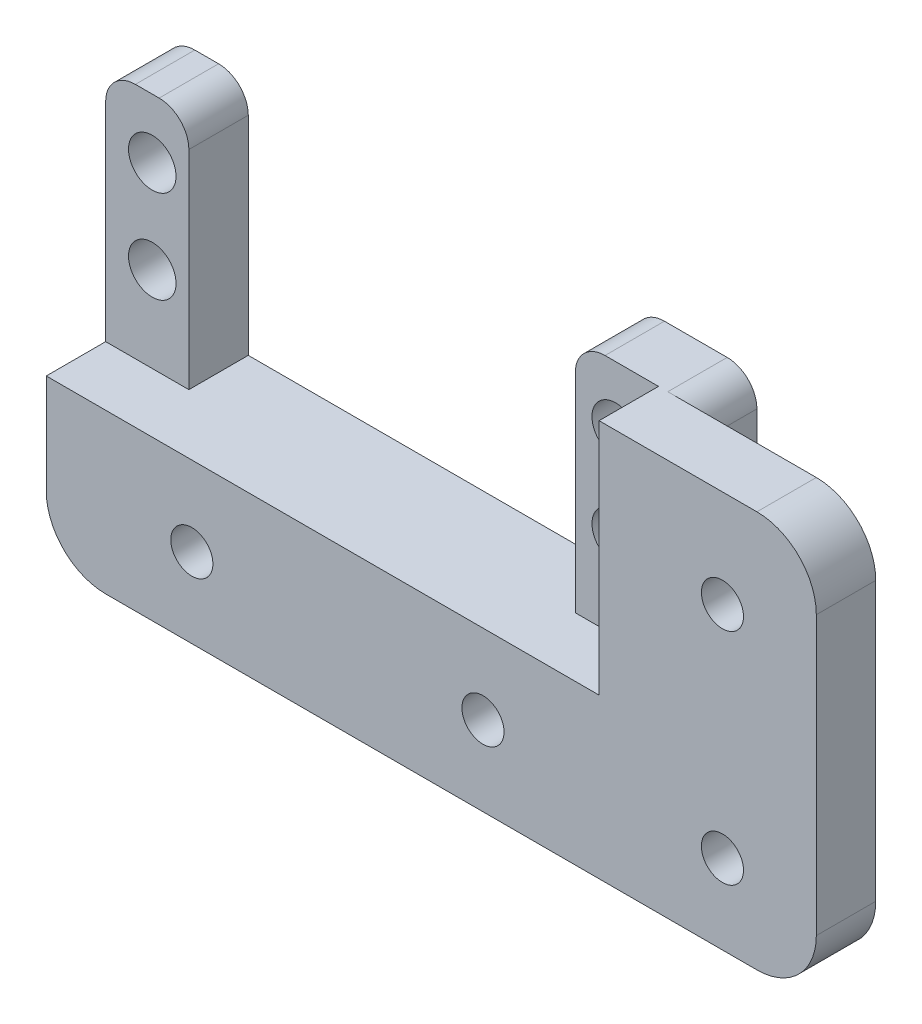
from build123d import *

# Parameters (mm, degrees)
BOSS_EXTRUDE1_DEPTH = 12.7
BOSS_EXTRUDE2_DEPTH = 25.4
SKETCH4_W           = 8.89
SKETCH4_H           = 6.35
BOSS_EXTRUDE3_DEPTH = 25.4
SKETCH5_R           = 2.54
CUT_EXTRUDE1_DEPTH  = 7.35
SKETCH6_W           = 20.066
SKETCH6_H           = 42.4
SKETCH6_R           = 2.25
BOSS_EXTRUDE4_DEPTH = 12.7
SKETCH7_R           = 6.35
SKETCH7_R_2         = 2.25
CUT_EXTRUDE2_DEPTH  = 6.35
SKETCH8_W           = 19.05
SKETCH8_H           = 42.4
CUT_EXTRUDE3_DEPTH  = 6.35
FILLET1_R           = 6.35
FILLET2_R           = 3.175


with BuildPart() as part:
    # Sketch1 → Boss-Extrude1 (new body)
    with BuildSketch(Plane.XY):
        Polygon((3833.667818581, -3.138), (3791.065892699, -3.138), (3781.25185564, -8.5), (3843.48185564, -8.5), align=None)
        with BuildLine():
            Line((3825.67435564, 0), (3799.05935564, 0))
            ThreePointArc((3799.05935564, 0), (3797.366063058, -2.180040562), (3794.834842884, -1.078795335))
            Line((3794.834842884, -1.078795335), (3791.065892699, -3.138))
            Line((3791.065892699, -3.138), (3833.667818581, -3.138))
            Line((3833.667818581, -3.138), (3829.898868396, -1.078795335))
            ThreePointArc((3829.898868396, -1.078795335), (3827.367648222, -2.180040562), (3825.67435564, 0))
        make_face()
        with BuildLine():
            Line((3843.48185564, -3.138), (3843.48185564, 0))
            Line((3843.48185564, 0), (3830.17435564, 0))
            ThreePointArc((3830.17435564, 0), (3830.104396202, -0.556707418), (3829.898868396, -1.078795335))
            Line((3829.898868396, -1.078795335), (3833.667818581, -3.138))
            Line((3833.667818581, -3.138), (3843.48185564, -3.138))
        make_face()
        Polygon((3812.36685564, 8.5), (3822.180892699, 3.138), (3843.48185564, 3.138), (3843.48185564, 8.5), align=None)
        with BuildLine():
            Line((3843.48185564, 3.138), (3822.180892699, 3.138))
            Line((3822.180892699, 3.138), (3825.949842884, 1.078795335))
            ThreePointArc((3825.949842884, 1.078795335), (3828.481063058, 2.180040562), (3830.17435564, 0))
            Line((3830.17435564, 0), (3843.48185564, 0))
            Line((3843.48185564, 0), (3843.48185564, 3.138))
        make_face()
        with BuildLine():
            Line((3822.180892699, 3.138), (3802.552818581, 3.138))
            Line((3802.552818581, 3.138), (3798.783868396, 1.078795335))
            ThreePointArc((3798.783868396, 1.078795335), (3798.989396202, 0.556707418), (3799.05935564, 0))
            Line((3799.05935564, 0), (3825.67435564, 0))
            ThreePointArc((3825.67435564, 0), (3825.744315078, 0.556707418), (3825.949842884, 1.078795335))
            Line((3825.949842884, 1.078795335), (3822.180892699, 3.138))
        make_face()
        Polygon((3812.36685564, 8.5), (3802.552818581, 3.138), (3822.180892699, 3.138), align=None)
        Polygon((3781.25185564, 8.5), (3781.25185564, 3.138), (3802.552818581, 3.138), (3812.36685564, 8.5), align=None)
        with BuildLine():
            Line((3802.552818581, 3.138), (3781.25185564, 3.138))
            Line((3781.25185564, 3.138), (3781.25185564, 0))
            Line((3781.25185564, 0), (3794.55935564, 0))
            ThreePointArc((3794.55935564, 0), (3796.252648222, 2.180040562), (3798.783868396, 1.078795335))
            Line((3798.783868396, 1.078795335), (3802.552818581, 3.138))
        make_face()
        with BuildLine():
            Line((3794.55935564, 0), (3781.25185564, 0))
            Line((3781.25185564, 0), (3781.25185564, -3.138))
            Line((3781.25185564, -3.138), (3791.065892699, -3.138))
            Line((3791.065892699, -3.138), (3794.834842884, -1.078795335))
            ThreePointArc((3794.834842884, -1.078795335), (3794.629315078, -0.556707418), (3794.55935564, 0))
        make_face()
        Polygon((3791.065892699, -3.138), (3781.25185564, -3.138), (3781.25185564, -8.5), align=None)
        Polygon((3843.48185564, -3.138), (3833.667818581, -3.138), (3843.48185564, -8.5), align=None)
    extrude(amount=BOSS_EXTRUDE1_DEPTH)

    # Sketch3 → Boss-Extrude2 (add)
    with BuildSketch(Plane(origin=(0, 8.5, 0), x_dir=(1, 0, 0), z_dir=(0, 1, 0))):
        Polygon((3831.44225564, 0), (3831.44225564, -6.35), (3840.33225564, -6.35), (3840.33225564, -12.7), (3843.48185564, -12.7), (3843.48185564, 0), align=None)
    extrude(amount=BOSS_EXTRUDE2_DEPTH)

    # Sketch4 → Boss-Extrude3 (add)
    with BuildSketch(Plane(origin=(0, 8.5, 0), x_dir=(1, 0, 0), z_dir=(0, 1, 0))):
        with Locations((3785.69685564, -3.175)):
            Rectangle(SKETCH4_W, SKETCH4_H)
    extrude(amount=BOSS_EXTRUDE3_DEPTH)

    # Sketch5 → Cut-Extrude1 (cut, through all)
    with BuildSketch(Plane.XY.offset(6.35)):
        with Locations((3835.76025564, 27.55)):
            Circle(SKETCH5_R)
        with Locations((3835.76025564, 17.644)):
            Circle(SKETCH5_R)
        with Locations((3786.23025564, 17.644)):
            Circle(SKETCH5_R)
        with Locations((3786.23025564, 27.55)):
            Circle(SKETCH5_R)
    extrude(amount=-CUT_EXTRUDE1_DEPTH, mode=Mode.SUBTRACT)

    # Sketch6 → Boss-Extrude4 (add)
    with BuildSketch(Plane(origin=(0, 0, 0), x_dir=(-1, 0, 0), z_dir=(0, 0, -1))):
        with Locations((-3853.51485564, 12.7)):
            Rectangle(SKETCH6_W, SKETCH6_H)
        with Locations((-3853.51485564, 0)):
            Circle(SKETCH6_R, mode=Mode.SUBTRACT)
        with Locations((-3853.51485564, 23.4830509)):
            Circle(SKETCH6_R, mode=Mode.SUBTRACT)
    extrude(amount=-BOSS_EXTRUDE4_DEPTH)

    # Sketch7 → Cut-Extrude2 (cut)
    with BuildSketch(Plane(origin=(0, 0, 0), x_dir=(-1, 0, 0), z_dir=(0, 0, -1))):
        with Locations((-3827.92435564, 0)):
            Circle(SKETCH7_R)
        with Locations((-3827.92435564, 0)):
            Circle(SKETCH7_R_2, mode=Mode.SUBTRACT)
        with Locations((-3796.80935564, 0)):
            Circle(SKETCH7_R)
        with Locations((-3796.80935564, 0)):
            Circle(SKETCH7_R_2, mode=Mode.SUBTRACT)
    extrude(amount=-CUT_EXTRUDE2_DEPTH, mode=Mode.SUBTRACT)

    # Sketch8 → Cut-Extrude3 (cut)
    with BuildSketch(Plane(origin=(0, 0, 0), x_dir=(-1, 0, 0), z_dir=(0, 0, -1))):
        with Locations((-3854.02285564, 12.7)):
            Rectangle(SKETCH8_W, SKETCH8_H)
    extrude(amount=-CUT_EXTRUDE3_DEPTH, mode=Mode.SUBTRACT)

    # Fillet1
    fillet1_edges = [part.edges().sort_by_distance(p)[0] for p in [
        (3844.49785564, -8.5, 3.175),
        (3781.25185564, -8.5, 6.35),
        (3863.54785564, 33.9, 9.525),
        (3863.54785564, -8.5, 9.525),
    ]]
    fillet(fillet1_edges, radius=FILLET1_R)

    # Fillet2
    fillet2_edges = [part.edges().sort_by_distance(p)[0] for p in [
        (3844.49785564, 33.9, 3.175),
        (3831.44225564, 33.9, 3.175),
        (3781.25185564, 33.9, 3.175),
        (3790.14185564, 33.9, 3.175),
    ]]
    fillet(fillet2_edges, radius=FILLET2_R)


solid = part.part
